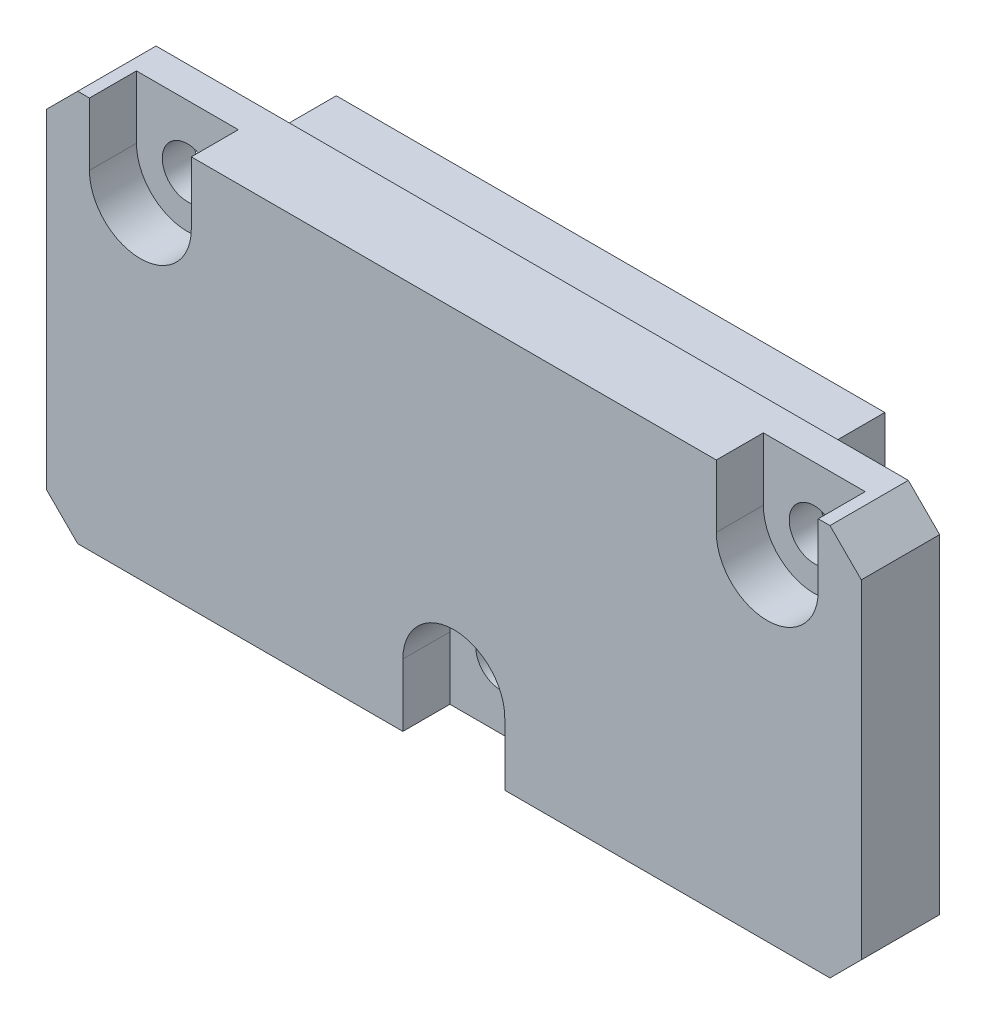
from build123d import *

# Parameters (mm, degrees)
SKETCH_1_W          = 52
SKETCH_1_H          = 25
EXTRUDE_1_DEPTH     = 5
CHAMFER_1_SIZE      = 2
SKETCH_2_W          = 35
SKETCH_2_H          = 15
EXTRUDE_2_DEPTH     = 5
CUT_EXTRUDE_1_DEPTH = 3
SKETCH_5_R          = 1.6
CUT_EXTRUDE_2_DEPTH = 8


with BuildPart() as part:
    # Эскиз1 → Бобышка-Вытянуть1 (new body)
    with BuildSketch(Plane.XY):
        Rectangle(SKETCH_1_W, SKETCH_1_H)
    extrude(amount=EXTRUDE_1_DEPTH)

    # Фаска1
    chamfer_1_edges = [part.edges().sort_by_distance(p)[0] for p in [
        (26, -12.5, 2.5),
        (-26, -12.5, 2.5),
        (-26, 12.5, 2.5),
        (26, 12.5, 2.5),
    ]]
    chamfer(chamfer_1_edges, length=CHAMFER_1_SIZE)

    # Эскиз2 → Бобышка-Вытянуть2 (add)
    with BuildSketch(Plane(origin=(0, 0, 0), x_dir=(-1, 0, 0), z_dir=(0, 0, -1))):
        with Locations((0, 3)):
            Rectangle(SKETCH_2_W, SKETCH_2_H)
    extrude(amount=EXTRUDE_2_DEPTH)

    # Эскиз3 → Вырез-Вытянуть1 (cut)
    with BuildSketch(Plane.XY.offset(5)):
        with BuildLine():
            Line((3.25, -12.5), (3.25, -8.5))
            ThreePointArc((3.25, -8.5), (0, -5.25), (-3.25, -8.5))
            Line((-3.25, -8.5), (-3.25, -12.5))
            Line((-3.25, -12.5), (3.25, -12.5))
        make_face()
        with BuildLine():
            Line((-23.25, 12.5), (-23.25, 8.5))
            ThreePointArc((-23.25, 8.5), (-20, 5.25), (-16.75, 8.5))
            Line((-16.75, 8.5), (-16.75, 12.5))
            Line((-16.75, 12.5), (-23.25, 12.5))
        make_face()
        with BuildLine():
            Line((16.75, 12.5), (16.75, 8.5))
            ThreePointArc((16.75, 8.5), (20, 5.25), (23.25, 8.5))
            Line((23.25, 8.5), (23.25, 12.5))
            Line((23.25, 12.5), (16.75, 12.5))
        make_face()
    extrude(amount=-CUT_EXTRUDE_1_DEPTH, mode=Mode.SUBTRACT)

    # Эскиз5 → Вырез-Вытянуть2 (cut, through all)
    with BuildSketch(Plane.XY.offset(2)):
        with Locations((0, -8.5)):
            Circle(SKETCH_5_R)
        with Locations((-20, 8.5)):
            Circle(SKETCH_5_R)
        with Locations((20, 8.5)):
            Circle(SKETCH_5_R)
    extrude(amount=-CUT_EXTRUDE_2_DEPTH, mode=Mode.SUBTRACT)


solid = part.part
